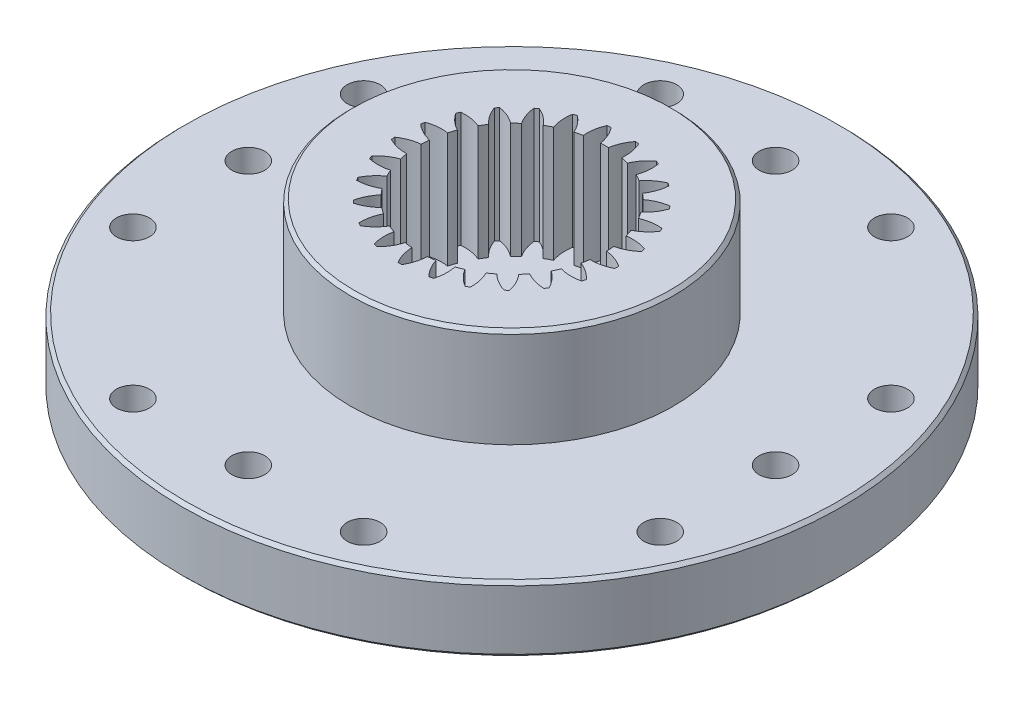
from build123d import *

# Parameters (mm, degrees)
SKETCH_1_R          = 10
EXTRUDE_1_DEPTH     = 2
SKETCH_2_R          = 4.9
EXTRUDE_2_DEPTH     = 3
SKETCH_3_R          = 0.5
CUT_EXTRUDE_1_DEPTH = 3
SKETCH_4_R          = 1.4
CUT_EXTRUDE_2_DEPTH = 16
SKETCH_4_3_R        = 4.35
SKETCH_4_3_R_2      = 2.9
CUT_EXTRUDE_3_DEPTH = 0.45
SKETCH_4_4_R        = 2.9
SKETCH_4_4_R_2      = 1.4
CUT_EXTRUDE_4_DEPTH = 0.95
SKETCH_6_R          = 1.4
CUT_EXTRUDE_5_DEPTH = 3.5
CHAMFER_1_SIZE      = 0.1


with BuildPart() as part:
    # ｽｹｯﾁ1 → ﾎﾞｽ - 押し出し1 (new body)
    with BuildSketch(Plane(origin=(0, 0, 0), x_dir=(1, 0, 0), z_dir=(0, 1, 0))):
        with Locations(Location((0, 0, 0), (0, 0, 270))):
            Circle(SKETCH_1_R)
    extrude(amount=EXTRUDE_1_DEPTH)

    # ｽｹｯﾁ2 → ﾎﾞｽ - 押し出し2 (add)
    with BuildSketch(Plane(origin=(0, 2, 0), x_dir=(1, 0, 0), z_dir=(0, 1, 0))):
        with Locations(Location((0, 0, 0), (0, 0, 270))):
            Circle(SKETCH_2_R)
    extrude(amount=EXTRUDE_2_DEPTH)

    # ｽｹｯﾁ3 → ｶｯﾄ - 押し出し1 (cut)
    with BuildSketch(Plane.XZ):
        with Locations(Location((-3.5, 8, 0), (0, 0, 270))):
            Circle(SKETCH_3_R)
        with Locations(Location((0, 8, 0), (0, 0, 270))):
            Circle(SKETCH_3_R)
        with Locations(Location((3.5, 8, 0), (0, 0, 270))):
            Circle(SKETCH_3_R)
        with Locations(Location((8, 0, 0), (0, 0, 270))):
            Circle(SKETCH_3_R)
        with Locations(Location((8, 3.5, 0), (0, 0, 270))):
            Circle(SKETCH_3_R)
        with Locations(Location((8, -3.5, 0), (0, 0, 270))):
            Circle(SKETCH_3_R)
        with Locations(Location((0, -8, 0), (0, 0, 270))):
            Circle(SKETCH_3_R)
        with Locations(Location((3.5, -8, 0), (0, 0, 270))):
            Circle(SKETCH_3_R)
        with Locations(Location((-3.5, -8, 0), (0, 0, 270))):
            Circle(SKETCH_3_R)
        with Locations(Location((-8, 0, 0), (0, 0, 270))):
            Circle(SKETCH_3_R)
        with Locations(Location((-8, -3.5, 0), (0, 0, 270))):
            Circle(SKETCH_3_R)
        with Locations(Location((-8, 3.5, 0), (0, 0, 270))):
            Circle(SKETCH_3_R)
    extrude(amount=-CUT_EXTRUDE_1_DEPTH, mode=Mode.SUBTRACT)

    # ｽｹｯﾁ4 → ｶｯﾄ - 押し出し2 (cut, through all)
    with BuildSketch(Plane.XZ):
        with Locations(Location((0, 0, 0), (0, 0, 270))):
            Circle(SKETCH_4_R)
    extrude(amount=-CUT_EXTRUDE_2_DEPTH, mode=Mode.SUBTRACT)

    # ｽｹｯﾁ4<3> → ｶｯﾄ - 押し出し3 (cut)
    with BuildSketch(Plane.XZ):
        with Locations(Location((0, 0, 0), (0, 0, 270))):
            Circle(SKETCH_4_3_R)
        with Locations(Location((0, 0, 0), (0, 0, 270))):
            Circle(SKETCH_4_3_R_2, mode=Mode.SUBTRACT)
    extrude(amount=-CUT_EXTRUDE_3_DEPTH, mode=Mode.SUBTRACT)

    # ｽｹｯﾁ4<4> → ｶｯﾄ - 押し出し4 (cut)
    with BuildSketch(Plane.XZ):
        with Locations(Location((0, 0, 0), (0, 0, 270))):
            Circle(SKETCH_4_4_R)
        with Locations(Location((0, 0, 0), (0, 0, 270))):
            Circle(SKETCH_4_4_R_2, mode=Mode.SUBTRACT)
    extrude(amount=-CUT_EXTRUDE_4_DEPTH, mode=Mode.SUBTRACT)

    # ｽｹｯﾁ6 → ｶｯﾄ - 押し出し5 (cut)
    with BuildSketch(Plane(origin=(0, 5, 0), x_dir=(1, 0, 0), z_dir=(0, 1, 0))):
        with BuildLine():
            ThreePointArc((0.584737306, 2.750020824), (0.573104806, 3.064374634), (0.483360636, 3.365870267))
            ThreePointArc((0.483360636, 3.365870267), (0.426183127, 3.37358683), (0.368882924, 3.380332165))
            ThreePointArc((0.368882924, 3.380332165), (0.206979317, 3.11062704), (0.11753566, 2.809042118))
            ThreePointArc((0.11753566, 2.809042118), (0, 2.8115), (-0.11753566, 2.809042118))
            ThreePointArc((-0.11753566, 2.809042118), (-0.206979317, 3.11062704), (-0.368882924, 3.380332165))
            ThreePointArc((-0.368882924, 3.380332165), (-0.426183127, 3.37358683), (-0.483360636, 3.365870267))
            ThreePointArc((-0.483360636, 3.365870267), (-0.573104806, 3.064374634), (-0.584737306, 2.750020824))
            ThreePointArc((-0.584737306, 2.750020824), (-0.699191618, 2.723171558), (-0.812423428, 2.691560964))
            ThreePointArc((-0.812423428, 2.691560964), (-0.974058169, 2.961427308), (-1.197948213, 3.182395362))
            ThreePointArc((-1.197948213, 3.182395362), (-1.251770729, 3.161611963), (-1.30523287, 3.139918361))
            ThreePointArc((-1.30523287, 3.139918361), (-1.317178647, 2.8255763), (-1.250269077, 2.518205608))
            ThreePointArc((-1.250269077, 2.518205608), (-1.354450455, 2.463736231), (-1.456263645, 2.404959136))
            ThreePointArc((-1.456263645, 2.404959136), (-1.679933363, 2.626150207), (-1.951742011, 2.784496953))
            ThreePointArc((-1.951742011, 2.784496953), (-1.998704972, 2.750981388), (-2.045092522, 2.716673837))
            ThreePointArc((-2.045092522, 2.716673837), (-1.978489309, 2.409236616), (-1.837241843, 2.128162273))
            ThreePointArc((-1.837241843, 2.128162273), (-1.924604188, 2.049495296), (-2.008601461, 1.967244881))
            ThreePointArc((-2.008601461, 1.967244881), (-2.280252166, 2.125862431), (-2.58290068, 2.211638361))
            ThreePointArc((-2.58290068, 2.211638361), (-2.620053231, 2.167496535), (-2.65645149, 2.122730704))
            ThreePointArc((-2.65645149, 2.122730704), (-2.515484211, 1.841515734), (-2.308773948, 1.604398675))
            ThreePointArc((-2.308773948, 1.604398675), (-2.373827963, 1.506477034), (-2.43473146, 1.405921395))
            ThreePointArc((-2.43473146, 1.405921395), (-2.737294339, 1.4919989), (-3.051766199, 1.499814396))
            ThreePointArc((-3.051766199, 1.499814396), (-3.076773909, 1.447819903), (-3.100895841, 1.395408594))
            ThreePointArc((-3.100895841, 1.395408594), (-2.894421989, 1.158085646), (-2.635237294, 0.979824808))
            ThreePointArc((-2.635237294, 0.979824808), (-2.673895396, 0.86880128), (-2.707878327, 0.756258697))
            ThreePointArc((-2.707878327, 0.756258697), (-3.022342242, 0.76438759), (-3.328878026, 0.693751577))
            ThreePointArc((-3.328878026, 0.693751577), (-3.340169567, 0.637171422), (-3.350499502, 0.58040783))
            ThreePointArc((-3.350499502, 0.58040783), (-3.091492589, 0.401888778), (-2.79611899, 0.293684944))
            ThreePointArc((-2.79611899, 0.293684944), (-2.805952147, 0.176535546), (-2.81087924, 0.059077484))
            ThreePointArc((-2.81087924, 0.059077484), (-3.117485266, -0.011253003), (-3.396824202, -0.155902205))
            ThreePointArc((-3.396824202, -0.155902205), (-3.393690087, -0.213512883), (-3.389578957, -0.271062092))
            ThreePointArc((-3.389578957, -0.271062092), (-3.094313339, -0.37956024), (-2.781310245, -0.410908224))
            ThreePointArc((-2.781310245, -0.410908224), (-2.761700605, -0.526822566), (-2.737262272, -0.641815785))
            ThreePointArc((-2.737262272, -0.641815785), (-3.016745226, -0.786186528), (-3.251335422, -0.995760078))
            ThreePointArc((-3.251335422, -0.995760078), (-3.233972578, -1.050781388), (-3.2156787, -1.105500186))
            ThreePointArc((-3.2156787, -1.105500186), (-2.902707002, -1.137160092), (-2.59174155, -1.089682518))
            ThreePointArc((-2.59174155, -1.089682518), (-2.543921258, -1.197078478), (-2.49165305, -1.302381408))
            ThreePointArc((-2.49165305, -1.302381408), (-2.726451989, -1.511721062), (-2.90155328, -1.773050683))
            ThreePointArc((-2.90155328, -1.773050683), (-2.871052678, -1.822025434), (-2.839725523, -1.870475638))
            ThreePointArc((-2.839725523, -1.870475638), (-2.528712909, -1.823307993), (-2.2393242, -1.699988052))
            ThreePointArc((-2.2393242, -1.699988052), (-2.166297982, -1.792117547), (-2.089484102, -1.881113616))
            ThreePointArc((-2.089484102, -1.881113616), (-2.264845745, -2.142268603), (-2.369455873, -2.438933993))
            ThreePointArc((-2.369455873, -2.438933993), (-2.327733979, -2.478784921), (-2.285341949, -2.517922226))
            ThreePointArc((-2.285341949, -2.517922226), (-1.995830484, -2.394890748), (-1.746201876, -2.203477084))
            ThreePointArc((-1.746201876, -2.203477084), (-1.652558237, -2.27455128), (-1.556025183, -2.341648539))
            ThreePointArc((-1.556025183, -2.341648539), (-1.660930914, -2.638209528), (-1.68847684, -2.951570111))
            ThreePointArc((-1.68847684, -2.951570111), (-1.638155193, -2.979793235), (-1.587361935, -3.007158501))
            ThreePointArc((-1.587361935, -3.007158501), (-1.337542689, -2.815993709), (-1.143359266, -2.568513547))
            ThreePointArc((-1.143359266, -2.568513547), (-1.03498218, -2.61406659), (-0.92479548, -2.655049071))
            ThreePointArc((-0.92479548, -2.655049071), (-0.952653686, -2.968382046), (-0.901404598, -3.278748223))
            ThreePointArc((-0.901404598, -3.278748223), (-0.845645092, -3.293570181), (-0.789642133, -3.307443947))
            ThreePointArc((-0.789642133, -3.307443947), (-0.595212168, -3.060157429), (-0.468675188, -2.772160857))
            ThreePointArc((-0.468675188, -2.772160857), (-0.352374386, -2.789330483), (-0.235457476, -2.801623106))
            ThreePointArc((-0.235457476, -2.801623106), (-0.184517722, -3.112040203), (-0.057693789, -3.399910526))
            ThreePointArc((-0.057693789, -3.399910526), (0, -3.4004), (0.057693789, -3.399910526))
            ThreePointArc((0.057693789, -3.399910526), (0.184517722, -3.112040203), (0.235457476, -2.801623106))
            ThreePointArc((0.235457476, -2.801623106), (0.352374386, -2.789330483), (0.468675188, -2.772160857))
            ThreePointArc((0.468675188, -2.772160857), (0.595212168, -3.060157429), (0.789642133, -3.307443947))
            ThreePointArc((0.789642133, -3.307443947), (0.845645092, -3.293570181), (0.901404598, -3.278748223))
            ThreePointArc((0.901404598, -3.278748223), (0.952653686, -2.968382046), (0.92479548, -2.655049071))
            ThreePointArc((0.92479548, -2.655049071), (1.03498218, -2.61406659), (1.143359266, -2.568513547))
            ThreePointArc((1.143359266, -2.568513547), (1.337542689, -2.815993709), (1.587361935, -3.007158501))
            ThreePointArc((1.587361935, -3.007158501), (1.638155193, -2.979793235), (1.68847684, -2.951570111))
            ThreePointArc((1.68847684, -2.951570111), (1.660930914, -2.638209528), (1.556025183, -2.341648539))
            ThreePointArc((1.556025183, -2.341648539), (1.652558237, -2.27455128), (1.746201876, -2.203477084))
            ThreePointArc((1.746201876, -2.203477084), (1.995830484, -2.394890748), (2.285341949, -2.517922226))
            ThreePointArc((2.285341949, -2.517922226), (2.327733979, -2.478784921), (2.369455873, -2.438933993))
            ThreePointArc((2.369455873, -2.438933993), (2.264845745, -2.142268603), (2.089484102, -1.881113616))
            ThreePointArc((2.089484102, -1.881113616), (2.166297982, -1.792117547), (2.2393242, -1.699988052))
            ThreePointArc((2.2393242, -1.699988052), (2.528712909, -1.823307993), (2.839725523, -1.870475638))
            ThreePointArc((2.839725523, -1.870475638), (2.871052678, -1.822025434), (2.90155328, -1.773050683))
            ThreePointArc((2.90155328, -1.773050683), (2.726451989, -1.511721062), (2.49165305, -1.302381408))
            ThreePointArc((2.49165305, -1.302381408), (2.543921258, -1.197078478), (2.59174155, -1.089682518))
            ThreePointArc((2.59174155, -1.089682518), (2.902707002, -1.137160092), (3.2156787, -1.105500186))
            ThreePointArc((3.2156787, -1.105500186), (3.233972578, -1.050781388), (3.251335422, -0.995760078))
            ThreePointArc((3.251335422, -0.995760078), (3.016745226, -0.786186528), (2.737262272, -0.641815785))
            ThreePointArc((2.737262272, -0.641815785), (2.761700605, -0.526822566), (2.781310245, -0.410908224))
            ThreePointArc((2.781310245, -0.410908224), (3.094313339, -0.37956024), (3.389578957, -0.271062092))
            ThreePointArc((3.389578957, -0.271062092), (3.393690087, -0.213512883), (3.396824202, -0.155902205))
            ThreePointArc((3.396824202, -0.155902205), (3.117485266, -0.011253003), (2.81087924, 0.059077484))
            ThreePointArc((2.81087924, 0.059077484), (2.805952147, 0.176535546), (2.79611899, 0.293684944))
            ThreePointArc((2.79611899, 0.293684944), (3.091492589, 0.401888778), (3.350499502, 0.58040783))
            ThreePointArc((3.350499502, 0.58040783), (3.340169567, 0.637171422), (3.328878026, 0.693751577))
            ThreePointArc((3.328878026, 0.693751577), (3.022342242, 0.76438759), (2.707878327, 0.756258697))
            ThreePointArc((2.707878327, 0.756258697), (2.673895396, 0.86880128), (2.635237294, 0.979824808))
            ThreePointArc((2.635237294, 0.979824808), (2.894421989, 1.158085646), (3.100895841, 1.395408594))
            ThreePointArc((3.100895841, 1.395408594), (3.076773909, 1.447819903), (3.051766199, 1.499814396))
            ThreePointArc((3.051766199, 1.499814396), (2.737294339, 1.4919989), (2.43473146, 1.405921395))
            ThreePointArc((2.43473146, 1.405921395), (2.373827963, 1.506477034), (2.308773948, 1.604398675))
            ThreePointArc((2.308773948, 1.604398675), (2.515484211, 1.841515734), (2.65645149, 2.122730704))
            ThreePointArc((2.65645149, 2.122730704), (2.620053231, 2.167496535), (2.58290068, 2.211638361))
            ThreePointArc((2.58290068, 2.211638361), (2.280252166, 2.125862431), (2.008601461, 1.967244881))
            ThreePointArc((2.008601461, 1.967244881), (1.924604188, 2.049495296), (1.837241843, 2.128162273))
            ThreePointArc((1.837241843, 2.128162273), (1.978489309, 2.409236616), (2.045092522, 2.716673837))
            ThreePointArc((2.045092522, 2.716673837), (1.998704972, 2.750981388), (1.951742011, 2.784496953))
            ThreePointArc((1.951742011, 2.784496953), (1.679933363, 2.626150207), (1.456263645, 2.404959136))
            ThreePointArc((1.456263645, 2.404959136), (1.354450455, 2.463736231), (1.250269077, 2.518205608))
            ThreePointArc((1.250269077, 2.518205608), (1.317178647, 2.8255763), (1.30523287, 3.139918361))
            ThreePointArc((1.30523287, 3.139918361), (1.251770729, 3.161611963), (1.197948213, 3.182395362))
            ThreePointArc((1.197948213, 3.182395362), (0.974058169, 2.961427308), (0.812423428, 2.691560964))
            ThreePointArc((0.812423428, 2.691560964), (0.699191618, 2.723171558), (0.584737306, 2.750020824))
        make_face()
        with Locations(Location((0, 0, 0), (0, 0, 90))):
            Circle(SKETCH_6_R, mode=Mode.SUBTRACT)
    extrude(amount=-CUT_EXTRUDE_5_DEPTH, mode=Mode.SUBTRACT)

    # 面取り1
    chamfer_1_edges = [part.edges().sort_by_distance(p)[0] for p in [
        (0, 0, -10),
        (0, 2, -10),
        (0, 5, -4.9),
    ]]
    chamfer(chamfer_1_edges, length=CHAMFER_1_SIZE)


solid = part.part
